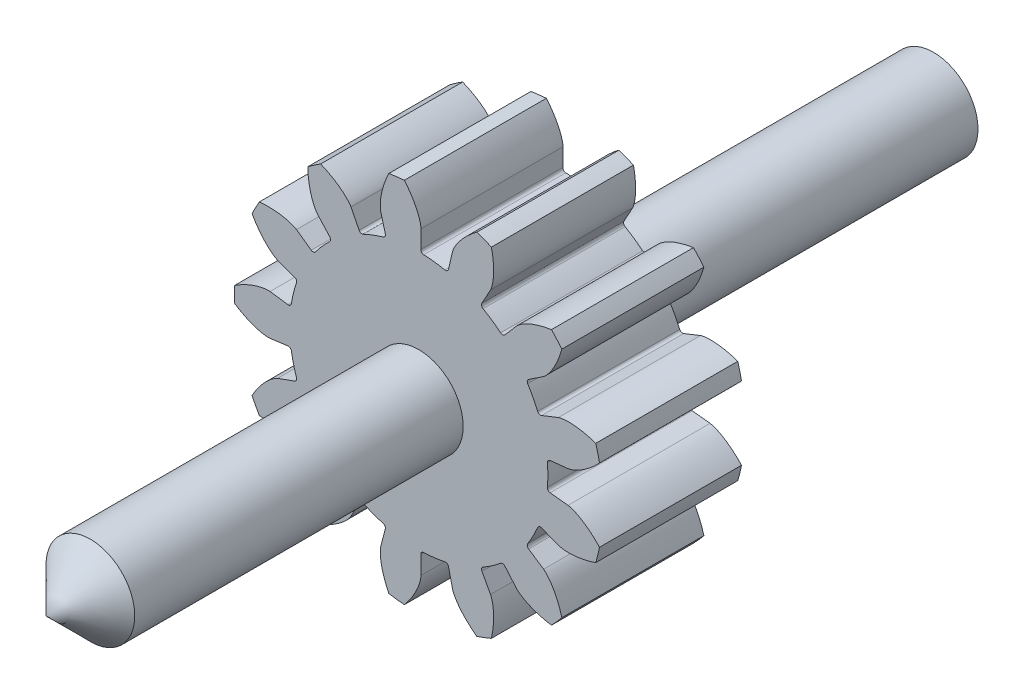
from build123d import *

# Parameters (mm, degrees)
SKETCH4_R                                  = 5.192307692
ADDENDUM_EXTRUDED_DEPTH                    = 2
F_1_2_TOOTH_CUT_DEPTH                      = 2
ROOTS_FILLET_R                             = 0.086538462
CIRCULAR_PATTERN_OF_TEETH_COUNT            = 13
CIRCULAR_PATTERN_OF_TEETH_COPY_1_DEPTH     = 2
CIRCULAR_PATTERN_OF_TEETH_COPY_2_DEPTH     = 2
CIRCULAR_PATTERN_OF_TEETH_COPY_3_DEPTH     = 2
CIRCULAR_PATTERN_OF_TEETH_COPY_4_DEPTH     = 2
CIRCULAR_PATTERN_OF_TEETH_COPY_5_DEPTH     = 2
CIRCULAR_PATTERN_OF_TEETH_COPY_6_DEPTH     = 2
CIRCULAR_PATTERN_OF_TEETH_COPY_7_DEPTH     = 2
CIRCULAR_PATTERN_OF_TEETH_COPY_8_DEPTH     = 2
CIRCULAR_PATTERN_OF_TEETH_COPY_9_DEPTH     = 2
CIRCULAR_PATTERN_OF_TEETH_COPY_10_DEPTH    = 2
CIRCULAR_PATTERN_OF_TEETH_COPY_11_DEPTH    = 2
CIRCULAR_PATTERN_OF_TEETH_COPY_12_DEPTH    = 2
ROOTS_FILLET_OF_CIRCULAR_PATTERN_OF_TEET_R = 0.086538462
SKETCH13_R                                 = 1.25
BOSS_EXTRUDE1_DEPTH                        = 12.5


with BuildPart() as part:
    # Sketch4 → Addendum Extruded (new body, symmetric)
    with BuildSketch(Plane.XY):
        Circle(SKETCH4_R)
    extrude(amount=ADDENDUM_EXTRUDED_DEPTH, both=True)

    # Tooth Profile Curve → 1/2 Tooth Cut (cut, symmetric)
    with BuildSketch(Plane.XY):
        with BuildLine():
            add(Edge.make_bspline(
                [(4.204884813, 0.447374226), (4.207986915, 0.447767482), (4.216659313, 0.449073359), (4.23293387, 0.452341976), (4.259259295, 0.458801259), (4.307616191, 0.473199127), (4.364553638, 0.494393137), (4.427550921, 0.522114623), (4.493778946, 0.55562082), (4.549412471, 0.586540476), (4.603920685, 0.619463007), (4.657284398, 0.654112641), (4.720751836, 0.698230781), (4.795178824, 0.754093335), (4.879554321, 0.823573282), (4.967774728, 0.903379768), (5.031761413, 0.966769685), (5.071820532, 1.008452054), (5.089641768, 1.027426806)],
                knots=[0, 0, 0, 0, 0, 0.005376748, 0.015083688, 0.02853182, 0.046610139, 0.092110525, 0.119476175, 0.146842495, 0.174208853, 0.201574955, 0.228941013, 0.256307345, 0.307035032, 0.361767351, 0.41649966, 0.46136011, 0.46136011, 0.46136011, 0.46136011, 0.46136011], degree=4))
            Line((4.204884813, 0.447374226), (3.614217078, 0.384530764))
            ThreePointArc((3.614217078, 0.384530764), (3.629512225, 0.19253571), (3.634615385, 0))
            Line((3.634615385, 0), (5.192307692, 0))
            ThreePointArc((5.192307692, 0), (5.166577459, 0.516271763), (5.089641768, 1.027426806))
        make_face()
    f_1_2_tooth_cut = extrude(amount=F_1_2_TOOTH_CUT_DEPTH, both=True, mode=Mode.SUBTRACT)

    # Mirror Tooth Cut: 1/2 Tooth Cut across plane
    add(f_1_2_tooth_cut.mirror(Plane.ZX), mode=Mode.SUBTRACT)

    # Roots Fillet
    roots_fillet_edges = [part.edges().sort_by_distance(p)[0] for p in [
        (3.614217078, 0.384530764, 0),
        (3.614217078, -0.384530764, 0),
    ]]
    fillet(roots_fillet_edges, radius=ROOTS_FILLET_R)

    # Circular Pattern of Teeth: 1/2 Tooth Cut ×13 about axis
    circular_pattern_of_teeth_axis = Axis((0, 0, -2), (0, 0, 1))
    for i in range(1, CIRCULAR_PATTERN_OF_TEETH_COUNT):
        add(f_1_2_tooth_cut.rotate(circular_pattern_of_teeth_axis, i * 360 / CIRCULAR_PATTERN_OF_TEETH_COUNT), mode=Mode.SUBTRACT)

    # Circular Pattern of Teeth copy 1 sketch → Circular Pattern of Teeth copy 1 (cut, symmetric)
    with BuildSketch(Plane(origin=(0, 0, 0), x_dir=(0.885456026, 0.464723172, 0), z_dir=(0, 0, 1))):
        with BuildLine():
            add(Edge.make_bspline(
                [(4.204884813, -0.447374226), (4.207986915, -0.447767482), (4.216659313, -0.449073359), (4.23293387, -0.452341976), (4.259259295, -0.458801259), (4.307616191, -0.473199127), (4.364553638, -0.494393137), (4.427550921, -0.522114623), (4.493778946, -0.55562082), (4.549412471, -0.586540476), (4.603920685, -0.619463007), (4.657284398, -0.654112641), (4.720751836, -0.698230781), (4.795178824, -0.754093335), (4.879554321, -0.823573282), (4.967774728, -0.903379768), (5.031761413, -0.966769685), (5.071820532, -1.008452054), (5.089641768, -1.027426806)],
                knots=[0, 0, 0, 0, 0, 0.005376748, 0.015083688, 0.02853182, 0.046610139, 0.092110525, 0.119476175, 0.146842495, 0.174208853, 0.201574955, 0.228941013, 0.256307345, 0.307035032, 0.361767351, 0.41649966, 0.46136011, 0.46136011, 0.46136011, 0.46136011, 0.46136011], degree=4))
            Line((4.204884813, -0.447374226), (3.614217078, -0.384530764))
            ThreePointArc((3.614217078, -0.384530764), (3.629512225, -0.19253571), (3.634615385, 0))
            Line((3.634615385, 0), (5.192307692, 0))
            ThreePointArc((5.192307692, 0), (5.166577459, -0.516271763), (5.089641768, -1.027426806))
        make_face()
    extrude(amount=CIRCULAR_PATTERN_OF_TEETH_COPY_1_DEPTH, both=True, mode=Mode.SUBTRACT)

    # Circular Pattern of Teeth copy 2 sketch → Circular Pattern of Teeth copy 2 (cut, symmetric)
    with BuildSketch(Plane(origin=(0, 0, 0), x_dir=(0.568064747, 0.822983866, 0), z_dir=(0, 0, 1))):
        with BuildLine():
            add(Edge.make_bspline(
                [(4.204884813, -0.447374226), (4.207986915, -0.447767482), (4.216659313, -0.449073359), (4.23293387, -0.452341976), (4.259259295, -0.458801259), (4.307616191, -0.473199127), (4.364553638, -0.494393137), (4.427550921, -0.522114623), (4.493778946, -0.55562082), (4.549412471, -0.586540476), (4.603920685, -0.619463007), (4.657284398, -0.654112641), (4.720751836, -0.698230781), (4.795178824, -0.754093335), (4.879554321, -0.823573282), (4.967774728, -0.903379768), (5.031761413, -0.966769685), (5.071820532, -1.008452054), (5.089641768, -1.027426806)],
                knots=[0, 0, 0, 0, 0, 0.005376748, 0.015083688, 0.02853182, 0.046610139, 0.092110525, 0.119476175, 0.146842495, 0.174208853, 0.201574955, 0.228941013, 0.256307345, 0.307035032, 0.361767351, 0.41649966, 0.46136011, 0.46136011, 0.46136011, 0.46136011, 0.46136011], degree=4))
            Line((4.204884813, -0.447374226), (3.614217078, -0.384530764))
            ThreePointArc((3.614217078, -0.384530764), (3.629512225, -0.19253571), (3.634615385, 0))
            Line((3.634615385, 0), (5.192307692, 0))
            ThreePointArc((5.192307692, 0), (5.166577459, -0.516271763), (5.089641768, -1.027426806))
        make_face()
    extrude(amount=CIRCULAR_PATTERN_OF_TEETH_COPY_2_DEPTH, both=True, mode=Mode.SUBTRACT)

    # Circular Pattern of Teeth copy 3 sketch → Circular Pattern of Teeth copy 3 (cut, symmetric)
    with BuildSketch(Plane(origin=(0, 0, 0), x_dir=(0.12053668, 0.992708874, 0), z_dir=(0, 0, 1))):
        with BuildLine():
            add(Edge.make_bspline(
                [(4.204884813, -0.447374226), (4.207986915, -0.447767482), (4.216659313, -0.449073359), (4.23293387, -0.452341976), (4.259259295, -0.458801259), (4.307616191, -0.473199127), (4.364553638, -0.494393137), (4.427550921, -0.522114623), (4.493778946, -0.55562082), (4.549412471, -0.586540476), (4.603920685, -0.619463007), (4.657284398, -0.654112641), (4.720751836, -0.698230781), (4.795178824, -0.754093335), (4.879554321, -0.823573282), (4.967774728, -0.903379768), (5.031761413, -0.966769685), (5.071820532, -1.008452054), (5.089641768, -1.027426806)],
                knots=[0, 0, 0, 0, 0, 0.005376748, 0.015083688, 0.02853182, 0.046610139, 0.092110525, 0.119476175, 0.146842495, 0.174208853, 0.201574955, 0.228941013, 0.256307345, 0.307035032, 0.361767351, 0.41649966, 0.46136011, 0.46136011, 0.46136011, 0.46136011, 0.46136011], degree=4))
            Line((4.204884813, -0.447374226), (3.614217078, -0.384530764))
            ThreePointArc((3.614217078, -0.384530764), (3.629512225, -0.19253571), (3.634615385, 0))
            Line((3.634615385, 0), (5.192307692, 0))
            ThreePointArc((5.192307692, 0), (5.166577459, -0.516271763), (5.089641768, -1.027426806))
        make_face()
    extrude(amount=CIRCULAR_PATTERN_OF_TEETH_COPY_3_DEPTH, both=True, mode=Mode.SUBTRACT)

    # Circular Pattern of Teeth copy 4 sketch → Circular Pattern of Teeth copy 4 (cut, symmetric)
    with BuildSketch(Plane(origin=(0, 0, 0), x_dir=(-0.354604887, 0.935016243, 0), z_dir=(0, 0, 1))):
        with BuildLine():
            add(Edge.make_bspline(
                [(4.204884813, -0.447374226), (4.207986915, -0.447767482), (4.216659313, -0.449073359), (4.23293387, -0.452341976), (4.259259295, -0.458801259), (4.307616191, -0.473199127), (4.364553638, -0.494393137), (4.427550921, -0.522114623), (4.493778946, -0.55562082), (4.549412471, -0.586540476), (4.603920685, -0.619463007), (4.657284398, -0.654112641), (4.720751836, -0.698230781), (4.795178824, -0.754093335), (4.879554321, -0.823573282), (4.967774728, -0.903379768), (5.031761413, -0.966769685), (5.071820532, -1.008452054), (5.089641768, -1.027426806)],
                knots=[0, 0, 0, 0, 0, 0.005376748, 0.015083688, 0.02853182, 0.046610139, 0.092110525, 0.119476175, 0.146842495, 0.174208853, 0.201574955, 0.228941013, 0.256307345, 0.307035032, 0.361767351, 0.41649966, 0.46136011, 0.46136011, 0.46136011, 0.46136011, 0.46136011], degree=4))
            Line((4.204884813, -0.447374226), (3.614217078, -0.384530764))
            ThreePointArc((3.614217078, -0.384530764), (3.629512225, -0.19253571), (3.634615385, 0))
            Line((3.634615385, 0), (5.192307692, 0))
            ThreePointArc((5.192307692, 0), (5.166577459, -0.516271763), (5.089641768, -1.027426806))
        make_face()
    extrude(amount=CIRCULAR_PATTERN_OF_TEETH_COPY_4_DEPTH, both=True, mode=Mode.SUBTRACT)

    # Circular Pattern of Teeth copy 5 sketch → Circular Pattern of Teeth copy 5 (cut, symmetric)
    with BuildSketch(Plane(origin=(0, 0, 0), x_dir=(-0.748510748, 0.663122658, 0), z_dir=(0, 0, 1))):
        with BuildLine():
            add(Edge.make_bspline(
                [(4.204884813, -0.447374226), (4.207986915, -0.447767482), (4.216659313, -0.449073359), (4.23293387, -0.452341976), (4.259259295, -0.458801259), (4.307616191, -0.473199127), (4.364553638, -0.494393137), (4.427550921, -0.522114623), (4.493778946, -0.55562082), (4.549412471, -0.586540476), (4.603920685, -0.619463007), (4.657284398, -0.654112641), (4.720751836, -0.698230781), (4.795178824, -0.754093335), (4.879554321, -0.823573282), (4.967774728, -0.903379768), (5.031761413, -0.966769685), (5.071820532, -1.008452054), (5.089641768, -1.027426806)],
                knots=[0, 0, 0, 0, 0, 0.005376748, 0.015083688, 0.02853182, 0.046610139, 0.092110525, 0.119476175, 0.146842495, 0.174208853, 0.201574955, 0.228941013, 0.256307345, 0.307035032, 0.361767351, 0.41649966, 0.46136011, 0.46136011, 0.46136011, 0.46136011, 0.46136011], degree=4))
            Line((4.204884813, -0.447374226), (3.614217078, -0.384530764))
            ThreePointArc((3.614217078, -0.384530764), (3.629512225, -0.19253571), (3.634615385, 0))
            Line((3.634615385, 0), (5.192307692, 0))
            ThreePointArc((5.192307692, 0), (5.166577459, -0.516271763), (5.089641768, -1.027426806))
        make_face()
    extrude(amount=CIRCULAR_PATTERN_OF_TEETH_COPY_5_DEPTH, both=True, mode=Mode.SUBTRACT)

    # Circular Pattern of Teeth copy 6 sketch → Circular Pattern of Teeth copy 6 (cut, symmetric)
    with BuildSketch(Plane(origin=(0, 0, 0), x_dir=(-0.970941817, 0.239315664, 0), z_dir=(0, 0, 1))):
        with BuildLine():
            add(Edge.make_bspline(
                [(4.204884813, -0.447374226), (4.207986915, -0.447767482), (4.216659313, -0.449073359), (4.23293387, -0.452341976), (4.259259295, -0.458801259), (4.307616191, -0.473199127), (4.364553638, -0.494393137), (4.427550921, -0.522114623), (4.493778946, -0.55562082), (4.549412471, -0.586540476), (4.603920685, -0.619463007), (4.657284398, -0.654112641), (4.720751836, -0.698230781), (4.795178824, -0.754093335), (4.879554321, -0.823573282), (4.967774728, -0.903379768), (5.031761413, -0.966769685), (5.071820532, -1.008452054), (5.089641768, -1.027426806)],
                knots=[0, 0, 0, 0, 0, 0.005376748, 0.015083688, 0.02853182, 0.046610139, 0.092110525, 0.119476175, 0.146842495, 0.174208853, 0.201574955, 0.228941013, 0.256307345, 0.307035032, 0.361767351, 0.41649966, 0.46136011, 0.46136011, 0.46136011, 0.46136011, 0.46136011], degree=4))
            Line((4.204884813, -0.447374226), (3.614217078, -0.384530764))
            ThreePointArc((3.614217078, -0.384530764), (3.629512225, -0.19253571), (3.634615385, 0))
            Line((3.634615385, 0), (5.192307692, 0))
            ThreePointArc((5.192307692, 0), (5.166577459, -0.516271763), (5.089641768, -1.027426806))
        make_face()
    extrude(amount=CIRCULAR_PATTERN_OF_TEETH_COPY_6_DEPTH, both=True, mode=Mode.SUBTRACT)

    # Circular Pattern of Teeth copy 7 sketch → Circular Pattern of Teeth copy 7 (cut, symmetric)
    with BuildSketch(Plane(origin=(0, 0, 0), x_dir=(-0.970941817, -0.239315664, 0), z_dir=(0, 0, 1))):
        with BuildLine():
            add(Edge.make_bspline(
                [(4.204884813, -0.447374226), (4.207986915, -0.447767482), (4.216659313, -0.449073359), (4.23293387, -0.452341976), (4.259259295, -0.458801259), (4.307616191, -0.473199127), (4.364553638, -0.494393137), (4.427550921, -0.522114623), (4.493778946, -0.55562082), (4.549412471, -0.586540476), (4.603920685, -0.619463007), (4.657284398, -0.654112641), (4.720751836, -0.698230781), (4.795178824, -0.754093335), (4.879554321, -0.823573282), (4.967774728, -0.903379768), (5.031761413, -0.966769685), (5.071820532, -1.008452054), (5.089641768, -1.027426806)],
                knots=[0, 0, 0, 0, 0, 0.005376748, 0.015083688, 0.02853182, 0.046610139, 0.092110525, 0.119476175, 0.146842495, 0.174208853, 0.201574955, 0.228941013, 0.256307345, 0.307035032, 0.361767351, 0.41649966, 0.46136011, 0.46136011, 0.46136011, 0.46136011, 0.46136011], degree=4))
            Line((4.204884813, -0.447374226), (3.614217078, -0.384530764))
            ThreePointArc((3.614217078, -0.384530764), (3.629512225, -0.19253571), (3.634615385, 0))
            Line((3.634615385, 0), (5.192307692, 0))
            ThreePointArc((5.192307692, 0), (5.166577459, -0.516271763), (5.089641768, -1.027426806))
        make_face()
    extrude(amount=CIRCULAR_PATTERN_OF_TEETH_COPY_7_DEPTH, both=True, mode=Mode.SUBTRACT)

    # Circular Pattern of Teeth copy 8 sketch → Circular Pattern of Teeth copy 8 (cut, symmetric)
    with BuildSketch(Plane(origin=(0, 0, 0), x_dir=(-0.748510748, -0.663122658, 0), z_dir=(0, 0, 1))):
        with BuildLine():
            add(Edge.make_bspline(
                [(4.204884813, -0.447374226), (4.207986915, -0.447767482), (4.216659313, -0.449073359), (4.23293387, -0.452341976), (4.259259295, -0.458801259), (4.307616191, -0.473199127), (4.364553638, -0.494393137), (4.427550921, -0.522114623), (4.493778946, -0.55562082), (4.549412471, -0.586540476), (4.603920685, -0.619463007), (4.657284398, -0.654112641), (4.720751836, -0.698230781), (4.795178824, -0.754093335), (4.879554321, -0.823573282), (4.967774728, -0.903379768), (5.031761413, -0.966769685), (5.071820532, -1.008452054), (5.089641768, -1.027426806)],
                knots=[0, 0, 0, 0, 0, 0.005376748, 0.015083688, 0.02853182, 0.046610139, 0.092110525, 0.119476175, 0.146842495, 0.174208853, 0.201574955, 0.228941013, 0.256307345, 0.307035032, 0.361767351, 0.41649966, 0.46136011, 0.46136011, 0.46136011, 0.46136011, 0.46136011], degree=4))
            Line((4.204884813, -0.447374226), (3.614217078, -0.384530764))
            ThreePointArc((3.614217078, -0.384530764), (3.629512225, -0.19253571), (3.634615385, 0))
            Line((3.634615385, 0), (5.192307692, 0))
            ThreePointArc((5.192307692, 0), (5.166577459, -0.516271763), (5.089641768, -1.027426806))
        make_face()
    extrude(amount=CIRCULAR_PATTERN_OF_TEETH_COPY_8_DEPTH, both=True, mode=Mode.SUBTRACT)

    # Circular Pattern of Teeth copy 9 sketch → Circular Pattern of Teeth copy 9 (cut, symmetric)
    with BuildSketch(Plane(origin=(0, 0, 0), x_dir=(-0.354604887, -0.935016243, 0), z_dir=(0, 0, 1))):
        with BuildLine():
            add(Edge.make_bspline(
                [(4.204884813, -0.447374226), (4.207986915, -0.447767482), (4.216659313, -0.449073359), (4.23293387, -0.452341976), (4.259259295, -0.458801259), (4.307616191, -0.473199127), (4.364553638, -0.494393137), (4.427550921, -0.522114623), (4.493778946, -0.55562082), (4.549412471, -0.586540476), (4.603920685, -0.619463007), (4.657284398, -0.654112641), (4.720751836, -0.698230781), (4.795178824, -0.754093335), (4.879554321, -0.823573282), (4.967774728, -0.903379768), (5.031761413, -0.966769685), (5.071820532, -1.008452054), (5.089641768, -1.027426806)],
                knots=[0, 0, 0, 0, 0, 0.005376748, 0.015083688, 0.02853182, 0.046610139, 0.092110525, 0.119476175, 0.146842495, 0.174208853, 0.201574955, 0.228941013, 0.256307345, 0.307035032, 0.361767351, 0.41649966, 0.46136011, 0.46136011, 0.46136011, 0.46136011, 0.46136011], degree=4))
            Line((4.204884813, -0.447374226), (3.614217078, -0.384530764))
            ThreePointArc((3.614217078, -0.384530764), (3.629512225, -0.19253571), (3.634615385, 0))
            Line((3.634615385, 0), (5.192307692, 0))
            ThreePointArc((5.192307692, 0), (5.166577459, -0.516271763), (5.089641768, -1.027426806))
        make_face()
    extrude(amount=CIRCULAR_PATTERN_OF_TEETH_COPY_9_DEPTH, both=True, mode=Mode.SUBTRACT)

    # Circular Pattern of Teeth copy 10 sketch → Circular Pattern of Teeth copy 10 (cut, symmetric)
    with BuildSketch(Plane(origin=(0, 0, 0), x_dir=(0.12053668, -0.992708874, 0), z_dir=(0, 0, 1))):
        with BuildLine():
            add(Edge.make_bspline(
                [(4.204884813, -0.447374226), (4.207986915, -0.447767482), (4.216659313, -0.449073359), (4.23293387, -0.452341976), (4.259259295, -0.458801259), (4.307616191, -0.473199127), (4.364553638, -0.494393137), (4.427550921, -0.522114623), (4.493778946, -0.55562082), (4.549412471, -0.586540476), (4.603920685, -0.619463007), (4.657284398, -0.654112641), (4.720751836, -0.698230781), (4.795178824, -0.754093335), (4.879554321, -0.823573282), (4.967774728, -0.903379768), (5.031761413, -0.966769685), (5.071820532, -1.008452054), (5.089641768, -1.027426806)],
                knots=[0, 0, 0, 0, 0, 0.005376748, 0.015083688, 0.02853182, 0.046610139, 0.092110525, 0.119476175, 0.146842495, 0.174208853, 0.201574955, 0.228941013, 0.256307345, 0.307035032, 0.361767351, 0.41649966, 0.46136011, 0.46136011, 0.46136011, 0.46136011, 0.46136011], degree=4))
            Line((4.204884813, -0.447374226), (3.614217078, -0.384530764))
            ThreePointArc((3.614217078, -0.384530764), (3.629512225, -0.19253571), (3.634615385, 0))
            Line((3.634615385, 0), (5.192307692, 0))
            ThreePointArc((5.192307692, 0), (5.166577459, -0.516271763), (5.089641768, -1.027426806))
        make_face()
    extrude(amount=CIRCULAR_PATTERN_OF_TEETH_COPY_10_DEPTH, both=True, mode=Mode.SUBTRACT)

    # Circular Pattern of Teeth copy 11 sketch → Circular Pattern of Teeth copy 11 (cut, symmetric)
    with BuildSketch(Plane(origin=(0, 0, 0), x_dir=(0.568064747, -0.822983866, 0), z_dir=(0, 0, 1))):
        with BuildLine():
            add(Edge.make_bspline(
                [(4.204884813, -0.447374226), (4.207986915, -0.447767482), (4.216659313, -0.449073359), (4.23293387, -0.452341976), (4.259259295, -0.458801259), (4.307616191, -0.473199127), (4.364553638, -0.494393137), (4.427550921, -0.522114623), (4.493778946, -0.55562082), (4.549412471, -0.586540476), (4.603920685, -0.619463007), (4.657284398, -0.654112641), (4.720751836, -0.698230781), (4.795178824, -0.754093335), (4.879554321, -0.823573282), (4.967774728, -0.903379768), (5.031761413, -0.966769685), (5.071820532, -1.008452054), (5.089641768, -1.027426806)],
                knots=[0, 0, 0, 0, 0, 0.005376748, 0.015083688, 0.02853182, 0.046610139, 0.092110525, 0.119476175, 0.146842495, 0.174208853, 0.201574955, 0.228941013, 0.256307345, 0.307035032, 0.361767351, 0.41649966, 0.46136011, 0.46136011, 0.46136011, 0.46136011, 0.46136011], degree=4))
            Line((4.204884813, -0.447374226), (3.614217078, -0.384530764))
            ThreePointArc((3.614217078, -0.384530764), (3.629512225, -0.19253571), (3.634615385, 0))
            Line((3.634615385, 0), (5.192307692, 0))
            ThreePointArc((5.192307692, 0), (5.166577459, -0.516271763), (5.089641768, -1.027426806))
        make_face()
    extrude(amount=CIRCULAR_PATTERN_OF_TEETH_COPY_11_DEPTH, both=True, mode=Mode.SUBTRACT)

    # Circular Pattern of Teeth copy 12 sketch → Circular Pattern of Teeth copy 12 (cut, symmetric)
    with BuildSketch(Plane(origin=(0, 0, 0), x_dir=(0.885456026, -0.464723172, 0), z_dir=(0, 0, 1))):
        with BuildLine():
            add(Edge.make_bspline(
                [(4.204884813, -0.447374226), (4.207986915, -0.447767482), (4.216659313, -0.449073359), (4.23293387, -0.452341976), (4.259259295, -0.458801259), (4.307616191, -0.473199127), (4.364553638, -0.494393137), (4.427550921, -0.522114623), (4.493778946, -0.55562082), (4.549412471, -0.586540476), (4.603920685, -0.619463007), (4.657284398, -0.654112641), (4.720751836, -0.698230781), (4.795178824, -0.754093335), (4.879554321, -0.823573282), (4.967774728, -0.903379768), (5.031761413, -0.966769685), (5.071820532, -1.008452054), (5.089641768, -1.027426806)],
                knots=[0, 0, 0, 0, 0, 0.005376748, 0.015083688, 0.02853182, 0.046610139, 0.092110525, 0.119476175, 0.146842495, 0.174208853, 0.201574955, 0.228941013, 0.256307345, 0.307035032, 0.361767351, 0.41649966, 0.46136011, 0.46136011, 0.46136011, 0.46136011, 0.46136011], degree=4))
            Line((4.204884813, -0.447374226), (3.614217078, -0.384530764))
            ThreePointArc((3.614217078, -0.384530764), (3.629512225, -0.19253571), (3.634615385, 0))
            Line((3.634615385, 0), (5.192307692, 0))
            ThreePointArc((5.192307692, 0), (5.166577459, -0.516271763), (5.089641768, -1.027426806))
        make_face()
    extrude(amount=CIRCULAR_PATTERN_OF_TEETH_COPY_12_DEPTH, both=True, mode=Mode.SUBTRACT)

    # Roots Fillet of Circular Pattern of Teet
    roots_fillet_of_circular_pattern_of_teet_edges = [part.edges().sort_by_distance(p)[0] for p in [
        (3.021529933, 2.020095507, 0),
        (3.378930646, 1.339125343, 0),
        (1.736646695, 3.192880714, 0),
        (2.369571923, 2.756003972, 0),
        (0.053918627, 3.634215428, 0),
        (0.81737283, 3.541515304, 0),
        (-1.641161548, 3.242995184, 0),
        (-0.922076529, 3.51570816, 0),
        (-2.960271391, 2.108843827, 0),
        (-2.450289267, 2.684494646, 0),
        (-3.601218733, 0.491581762, 0),
        (-3.417170263, 1.238295759, 0),
        (-3.417170263, -1.238295759, 0),
        (-3.601218733, -0.491581762, 0),
        (-2.450289267, -2.684494646, 0),
        (-2.960271391, -2.108843827, 0),
        (-0.922076529, -3.51570816, 0),
        (-1.641161548, -3.242995184, 0),
        (0.81737283, -3.541515304, 0),
        (0.053918627, -3.634215428, 0),
        (2.369571923, -2.756003972, 0),
        (1.736646695, -3.192880714, 0),
        (3.378930646, -1.339125343, 0),
        (3.021529933, -2.020095507, 0),
    ]]
    fillet(roots_fillet_of_circular_pattern_of_teet_edges, radius=ROOTS_FILLET_OF_CIRCULAR_PATTERN_OF_TEET_R)

    # Sketch13 → Boss-Extrude1 (add, symmetric)
    with BuildSketch(Plane.XY):
        Circle(SKETCH13_R)
    extrude(amount=BOSS_EXTRUDE1_DEPTH, both=True)

    # Sketch14 one side → Cut-Revolve4 (revolve, cut)
    with BuildSketch(Plane(origin=(0, 0, 0), x_dir=(0, 0, -1), z_dir=(1, 0, 0))):
        Polygon((-13.509008321, 2.4547615), (-13.509008321, 0), (-12.5, 0), (-10.0452385, 2.4547615), align=None)
    revolve(axis=Axis((0, 0, 16.300532732), (0, 0, -1)), mode=Mode.SUBTRACT)


solid = part.part
